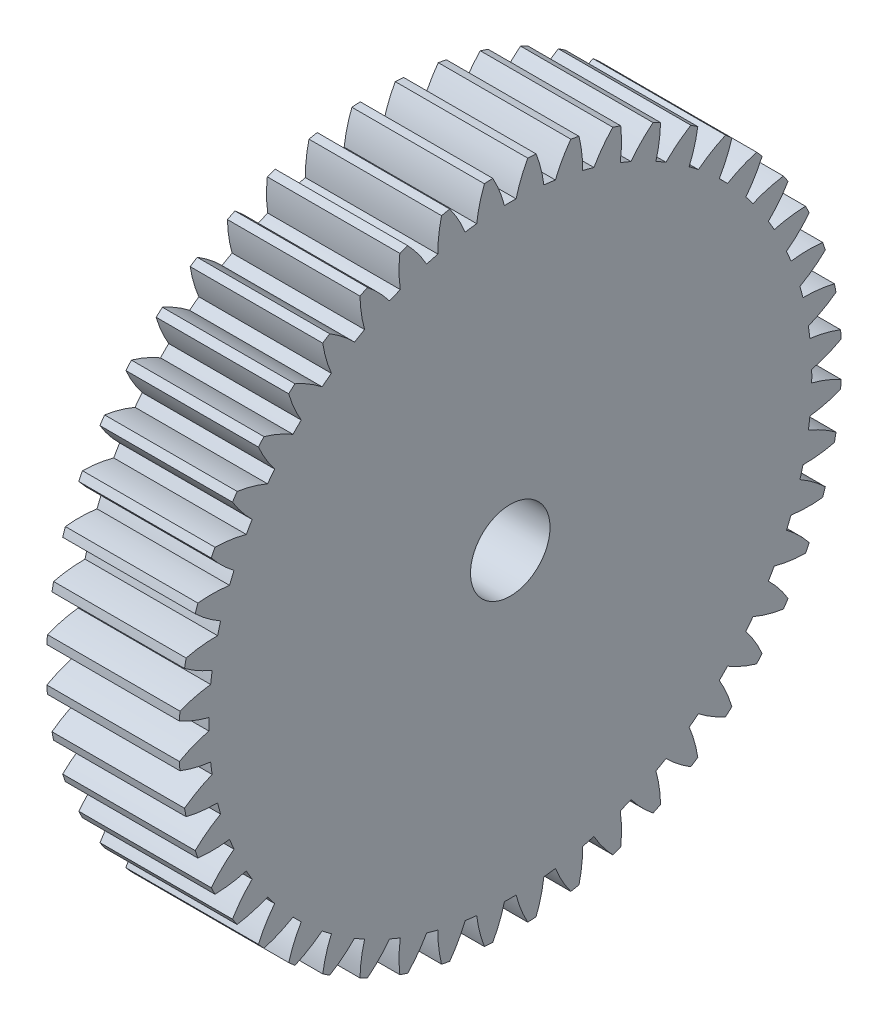
from build123d import *

# Parameters (mm, degrees)
BASPROSKE_W        = 10
BASPROSKE_H        = 25
TOOTHCUT_DEPTH     = 37.742346142
TEETHCUTS_COUNT    = 48
TEETHCUTS_ANGLE    = 352.5
BORSKE_R           = 2.5
BORE_DEPTH         = 50.0000508
SKETCH1_R          = 3
CUT_EXTRUDE1_DEPTH = 37.694892247


with BuildPart() as part:
    # BasProSke → Base-Revolve (revolve)
    with BuildSketch(Plane(origin=(0, 0, 0), x_dir=(1, 0, 0), z_dir=(0, 1, 0)), mode=Mode.PRIVATE) as base_revolve_sk:
        with Locations((5, 12.5)):
            Rectangle(BASPROSKE_W, BASPROSKE_H)
    revolve(base_revolve_sk.sketch.rotate(Axis((-10, 0, 0), (1, 0, 0)), 180), axis=Axis((-10, 0, 0), (1, 0, 0)))

    # TooCutSke → ToothCut (cut, through all)
    with BuildSketch(Plane(origin=(0, 0, 0), x_dir=(0, 0, -1), z_dir=(1, 0, 0))):
        with BuildLine():
            ThreePointArc((0.439519311, 22.744753764), (0, 22.749), (-0.439519311, 22.744753764))
            ThreePointArc((-0.439519311, 22.744753764), (-0.815652087, 23.895542925), (-1.33363602, 24.989839138))
            ThreePointArc((-1.33363602, 24.989839138), (0, 25.0254), (1.33363602, 24.989839138))
            ThreePointArc((1.33363602, 24.989839138), (0.815652087, 23.895542925), (0.439519311, 22.744753764))
        make_face()
    toothcut = extrude(amount=TOOTHCUT_DEPTH, mode=Mode.SUBTRACT)

    # TeethCuts: ToothCut ×48 about axis
    teethcuts_axis = Axis((-10, 0, 0), (1, 0, 0))
    for i in range(1, TEETHCUTS_COUNT):
        add(toothcut.rotate(teethcuts_axis, i * TEETHCUTS_ANGLE / (TEETHCUTS_COUNT - 1)), mode=Mode.SUBTRACT)

    # BorSke → Bore (cut, symmetric)
    with BuildSketch(Plane(origin=(0, 0, 0), x_dir=(0, 0, -1), z_dir=(1, 0, 0))):
        with Locations(Location((0, 0, 0), (0, 0, 180))):
            Circle(BORSKE_R)
    extrude(amount=BORE_DEPTH, both=True, mode=Mode.SUBTRACT)

    # Sketch1 → Cut-Extrude1 (cut, through all)
    with BuildSketch(Plane(origin=(10, 0, 0), x_dir=(0, 0, -1), z_dir=(1, 0, 0))):
        Circle(SKETCH1_R)
    extrude(amount=-CUT_EXTRUDE1_DEPTH, mode=Mode.SUBTRACT)


solid = part.part
